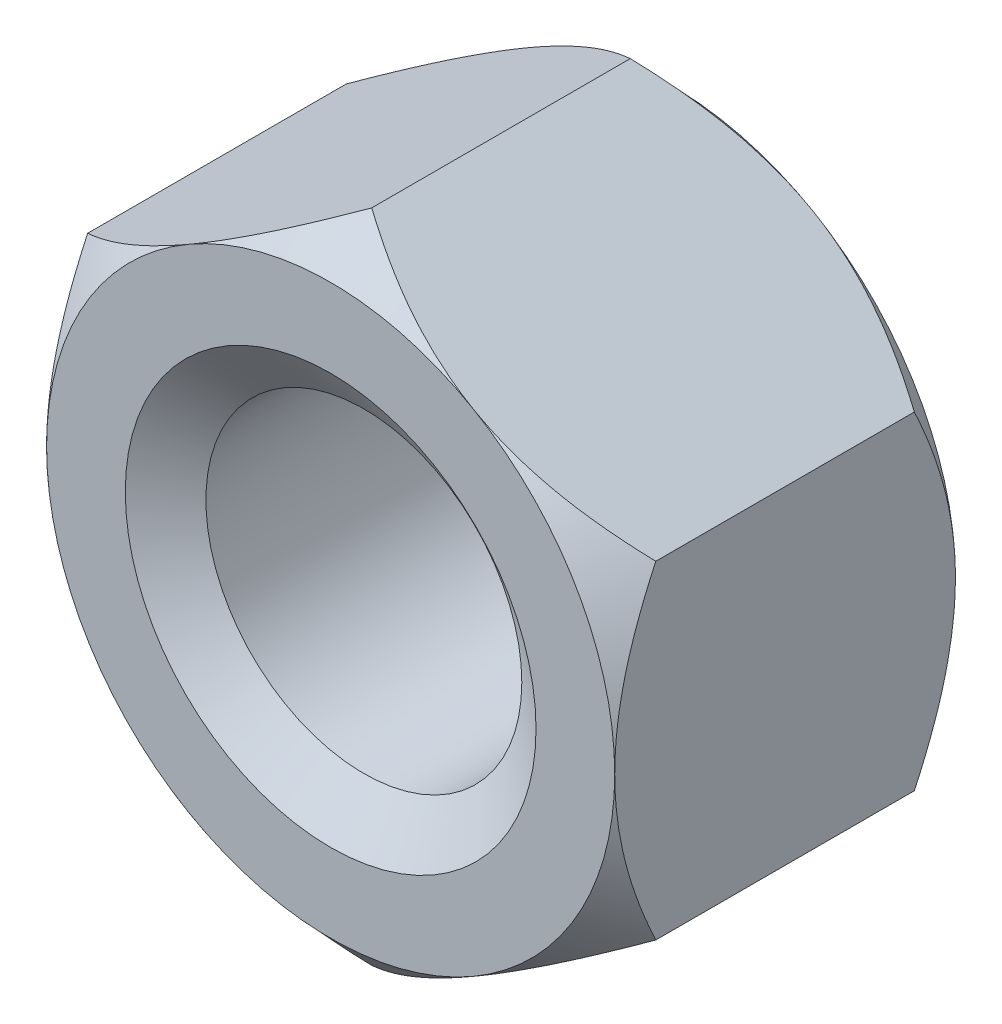
from build123d import *

# Parameters (mm, degrees)
BASENUTSKE_R  = 3.96875
BASENUT_DEPTH = 8.5598


with BuildPart() as part:
    # BaseNutSke → BaseNut (new body)
    with BuildSketch(Plane.XY):
        Polygon((7.1374, 4.120779811), (7.1374, -4.120779811), (0, -8.241559623), (-7.1374, -4.120779811), (-7.1374, 4.120779811), (0, 8.241559623), align=None)
        Circle(BASENUTSKE_R, mode=Mode.SUBTRACT)
    extrude(amount=-BASENUT_DEPTH)

    # Sketch3 → Double-Chamfer (revolve, cut)
    with BuildSketch(Plane(origin=(0, 0, 0), x_dir=(0, 0, -1), z_dir=(1, 0, 0))):
        Polygon((8.5598, 7.1374), (7.527798, 8.241559623), (7.527798, 20.941559623), (21.2598, 20.941559623), (21.2598, 7.1374), align=None)
        Polygon((1.032002, 20.941559623), (-12.7, 20.941559623), (-12.7, 7.1374), (0, 7.1374), (1.032002, 8.241559623), align=None)
    revolve(axis=Axis((0, 0, 0), (0, 0, -1)), mode=Mode.SUBTRACT)

    # Sketch5 → EndChamfer (revolve, cut)
    with BuildSketch(Plane(origin=(0, 0, 0), x_dir=(0, 0, -1), z_dir=(1, 0, 0))):
        Polygon((8.5344, 5.16001), (7.616857845, 3.849624), (8.5852, 3.849624), (8.5852, 5.16001), align=None)
        Polygon((-0.0508, 5.16001), (0, 5.16001), (0.917542155, 3.849624), (-0.0508, 3.849624), align=None)
    revolve(axis=Axis((0, 0, -25.037505729), (0, 0, -1)), mode=Mode.SUBTRACT)


solid = part.part
